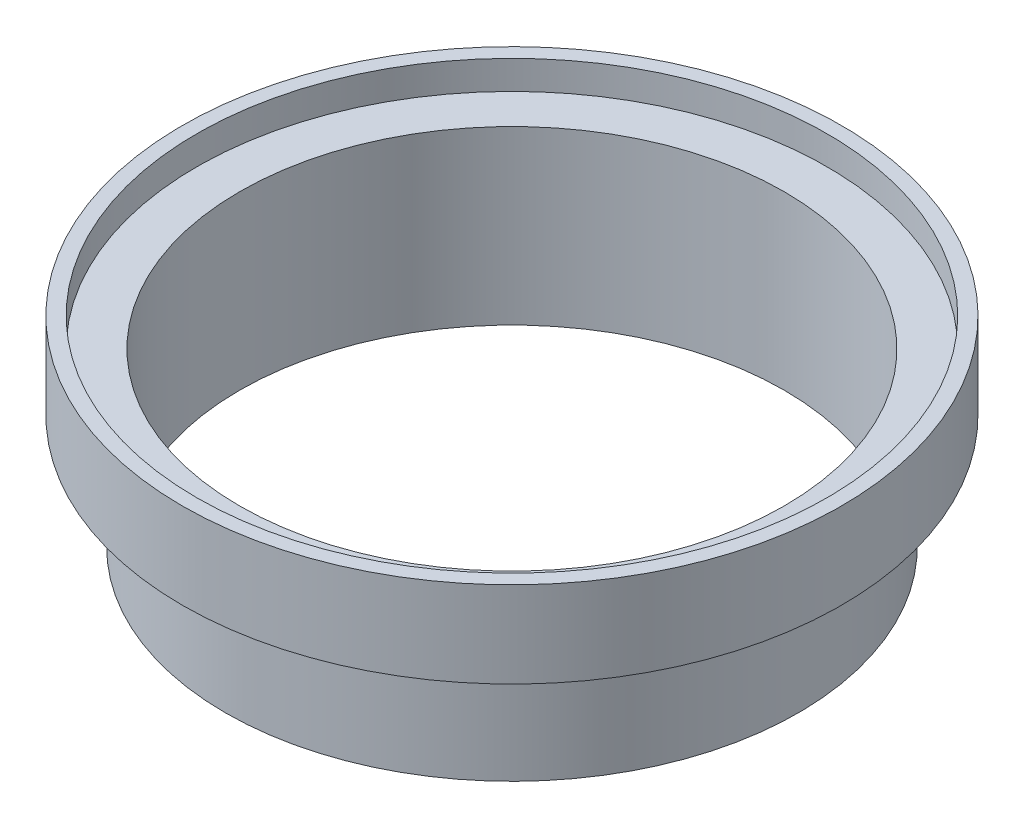
from build123d import *


with BuildPart() as part:
    # Sketch1 → Revolve1 (revolve)
    with BuildSketch(Plane.XY):
        Polygon((-60.325, 0), (-60.325, 38.1), (-69.85, 38.1), (-69.85, 44.45), (-73.025, 44.45), (-73.025, 25.4), (-63.5, 25.4), (-63.5, 0), align=None)
    revolve(axis=Axis((0, 65.052154419, 0), (0, -1, 0)))


solid = part.part
